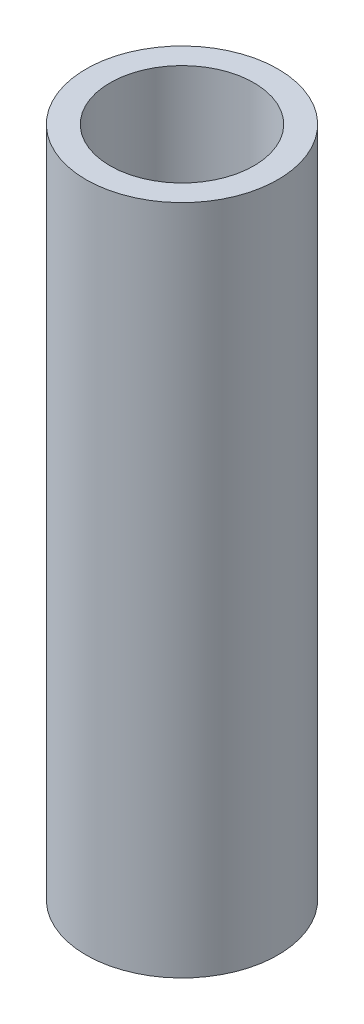
from build123d import *

# Parameters (mm, degrees)
SKETCH2_R           = 12.7
SKETCH2_R_2         = 9.525
BOSS_EXTRUDE1_DEPTH = 88.9


with BuildPart() as part:
    # Sketch2 → Boss-Extrude1 (new body)
    with BuildSketch(Plane(origin=(0, 0, 0), x_dir=(1, 0, 0), z_dir=(0, 1, 0))):
        with Locations((-14.567556118, 0)):
            Circle(SKETCH2_R)
        with Locations((-14.567556118, 0)):
            Circle(SKETCH2_R_2, mode=Mode.SUBTRACT)
    extrude(amount=BOSS_EXTRUDE1_DEPTH)


solid = part.part
